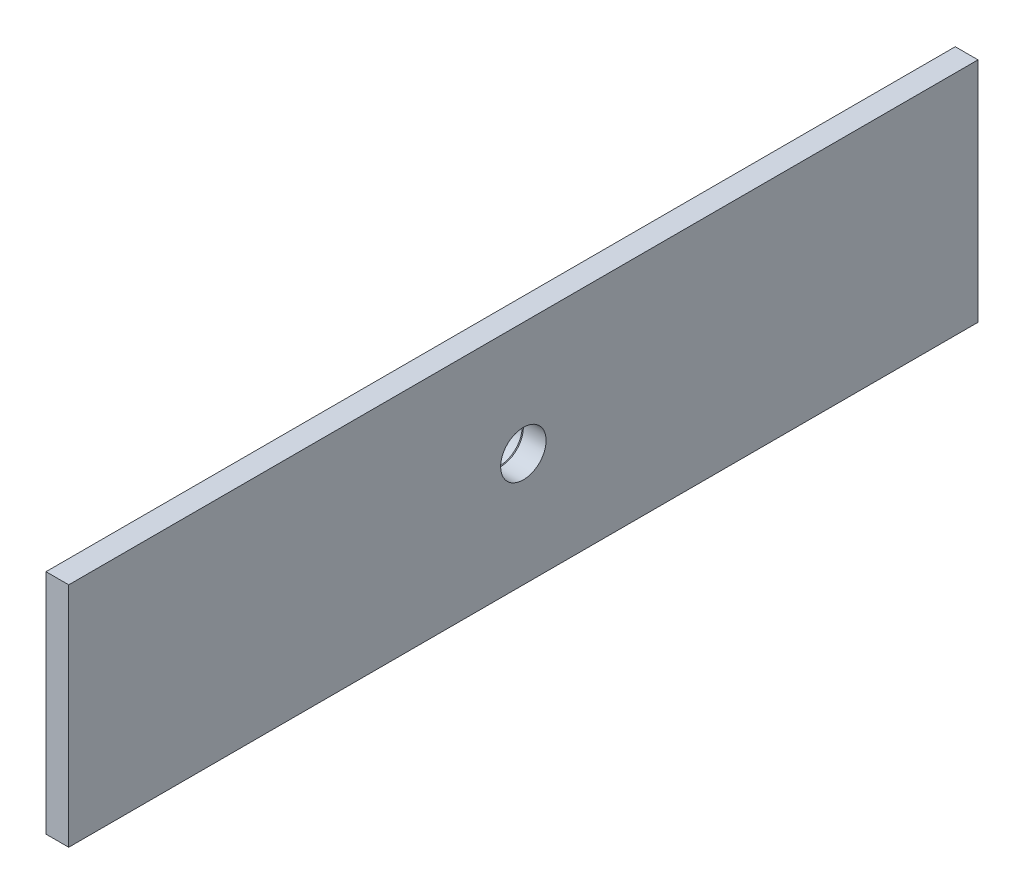
from build123d import *

# Parameters (mm, degrees)
SKETCH1_W                      = 5
SKETCH1_H                      = 20
CUT_EXTRUDE1_REACH             = 2.2
SKETCH2_W                      = 2
SKETCH2_H                      = 1
F_20_0_20_DIAMETER_HOLE1_D     = 20
F_20_0_20_DIAMETER_HOLE1_DEPTH = 5
F_5_0_5_DIAMETER_HOLE1_D       = 5
F_5_0_5_DIAMETER_HOLE1_DEPTH   = 5
F_4_2_4_2_DIAMETER_HOLE1_D     = 4.2
F_4_2_4_2_DIAMETER_HOLE1_DEPTH = 5
CHAMFER1_SIZE                  = 0.5
CHAMFER1_SIZE2                 = 0.866025404
CHAMFER2_SIZE                  = 0.5
SKETCH9_W                      = 400
SKETCH9_H                      = 100
SKETCH9_R                      = 10
BOSS_EXTRUDE1_DEPTH            = 10


with BuildPart() as part:
    # Sketch1 → Revolve1 (revolve)
    with BuildSketch(Plane.XY.offset(889.1)):
        with Locations((530.5, 10)):
            Rectangle(SKETCH1_W, SKETCH1_H)
    revolve(axis=Axis((528, 0, 889.1), (1, 0, 0)))

    # Sketch2 → Cut-Extrude1 (cut, up to next)
    with BuildSketch(Plane(origin=(0, 0, 908.9), x_dir=(-1, 0, 0), z_dir=(0, 0, -1)), mode=Mode.PRIVATE) as cut_extrude1_sk1:
        with Locations((-529.5, 0)):
            Rectangle(SKETCH2_W, SKETCH2_H)
    cut_extrude1_tool1 = extrude(cut_extrude1_sk1.sketch, amount=-CUT_EXTRUDE1_REACH, mode=Mode.PRIVATE) & part.part
    add(cut_extrude1_tool1.solids().sort_by_distance((529.5, 0, 908.9))[0], mode=Mode.SUBTRACT)

    # Ø20.0 (20) Diameter Hole1
    with Locations(Plane(origin=(533, 0, 0), x_dir=(0, 0, -1), z_dir=(1, 0, 0))):
        with Locations((-889.1, 0)):
            Hole(F_20_0_20_DIAMETER_HOLE1_D / 2, depth=F_20_0_20_DIAMETER_HOLE1_DEPTH)

    # Ø5.0 (5) Diameter Hole1
    with Locations(Plane.ZY.offset(-528)):
        with Locations((904.85, 0)):
            Hole(F_5_0_5_DIAMETER_HOLE1_D / 2, depth=F_5_0_5_DIAMETER_HOLE1_DEPTH)

    # Ø4.2 (4.2) Diameter Hole1
    with Locations(Plane.ZY.offset(-528)):
        with Locations((900.236931804, 11.136931804), (877.963068196, -11.136931804), (877.963068196, 11.136931804), (900.236931804, -11.136931804)):
            Hole(F_4_2_4_2_DIAMETER_HOLE1_D / 2, depth=F_4_2_4_2_DIAMETER_HOLE1_DEPTH)

    # Chamfer1
    chamfer1_edges = [part.edges().sort_by_distance(p)[0] for p in [
        (533, -20, 889.1),
    ]]
    chamfer1_side = [part.faces().sort_by_distance(p)[0] for p in [
        (533, -19.434314575, 889.1),
    ]]
    chamfer(chamfer1_edges, length=CHAMFER1_SIZE, length2=CHAMFER1_SIZE2, reference=chamfer1_side[0])

    # Chamfer2
    chamfer2_edges = [part.edges().sort_by_distance(p)[0] for p in [
        (533, 0, 879.1),
    ]]
    chamfer(chamfer2_edges, length=CHAMFER2_SIZE)

    # Sketch9 → Boss-Extrude1 (add)
    with BuildSketch(Plane(origin=(533, 0, 0), x_dir=(0, 0, -1), z_dir=(1, 0, 0))):
        with Locations((-889.1, 0)):
            Rectangle(SKETCH9_W, SKETCH9_H)
        with Locations((-889.1, 0)):
            Circle(SKETCH9_R, mode=Mode.SUBTRACT)
    extrude(amount=BOSS_EXTRUDE1_DEPTH)


solid = part.part
